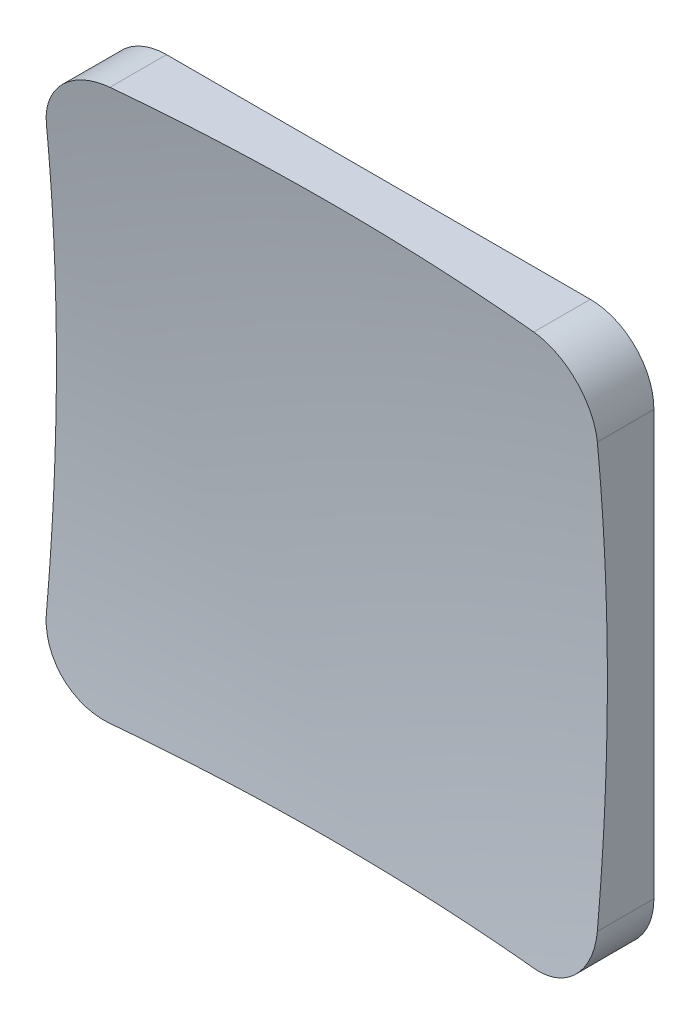
from build123d import *

# Parameters (mm, degrees)
SKETCH1_W           = 130
SKETCH1_H           = 130
BOSS_EXTRUDE1_DEPTH = 15
FILLET1_R           = 15
BOSS_EXTRUDE3_DEPTH = 20
BOSS_EXTRUDE4_DEPTH = 23
CUT_EXTRUDE1_DEPTH  = 50
CUT_EXTRUDE2_DEPTH  = 50
SKETCH10_R          = 3
CUT_EXTRUDE3_DEPTH  = 10


with BuildPart() as part:
    # Sketch1 → Boss-Extrude1 (new body)
    with BuildSketch(Plane.XY):
        Rectangle(SKETCH1_W, SKETCH1_H)
    extrude(amount=BOSS_EXTRUDE1_DEPTH)

    # Fillet1
    fillet1_edges = [part.edges().sort_by_distance(p)[0] for p in [
        (65, -65, 7.5),
        (-65, -65, 7.5),
        (-65, 65, 7.5),
        (65, 65, 7.5),
    ]]
    fillet(fillet1_edges, radius=FILLET1_R)

    # Sketch5 → Boss-Extrude3 (add)
    with BuildSketch(Plane.XY.offset(15)):
        Polygon((-65, 65), (65, -65), (70.504249196, -59.495750804), (-59.495750804, 70.504249196), align=None)
    extrude(amount=BOSS_EXTRUDE3_DEPTH)

    # Sketch6 → Cut-Revolve2 (revolve, cut)
    with BuildSketch(Plane(origin=(0, 0, 0), x_dir=(0, 0, 1), z_dir=(-0.707106781, -0.707106781, 0))):
        with BuildLine():
            Line((15, 91.923881554), (15, 99.514365428))
            Line((15, 99.514365428), (45.882557295, 99.514365428))
            Line((45.882557295, 99.514365428), (45.882557295, 91.923881554))
            Line((45.882557295, 91.923881554), (45.882557295, 0))
            Line((45.882557295, 0), (6.998120304, 0))
            ThreePointArc((6.998120304, 0), (9.00236559, 46.135750993), (15, 91.923881554))
        make_face()
    revolve(axis=Axis((0, 0, 45.882557295), (0, 0, 1)), mode=Mode.SUBTRACT)

    # Sketch7 → Boss-Extrude4 (add)
    with BuildSketch(Plane(origin=(0, 0, 0), x_dir=(-1, 0, 0), z_dir=(0, 0, -1))):
        Polygon((-22, -65), (22, -65), (22, -22), (65, -22), (65, 22), (22, 22), (22, 65), (-22, 65), (-22, 22), (-65, 22), (-65, -22), (-22, -22), align=None)
    extrude(amount=BOSS_EXTRUDE4_DEPTH)

    # Sketch8 → Cut-Extrude1 (cut)
    with BuildSketch(Plane.XZ.offset(22)):
        Polygon((-65, 0), (-55.807611845, -9.192388155), (-45.807611845, -9.192388155), (-40, -23), (0, -40.620002029), (40, -23), (45.807611845, -9.192388155), (55.807611845, -9.192388155), (65, 0), (68.211957708, -1.350979723), (68.682657398, -47.498818865), (-34.338090691, -46.266881669), (-70.140917764, -27.552380355), align=None)
    extrude(amount=-CUT_EXTRUDE1_DEPTH, mode=Mode.SUBTRACT)

    # Sketch9 → Cut-Extrude2 (cut)
    with BuildSketch(Plane(origin=(22, 0, 0), x_dir=(0, 0, -1), z_dir=(1, 0, 0))):
        Polygon((0, 65), (9.192388155, 55.807611845), (9.192388155, 45.807611845), (23, 40), (23, 65), align=None)
    extrude(amount=-CUT_EXTRUDE2_DEPTH, mode=Mode.SUBTRACT)

    # Sketch10 → Cut-Extrude3 (cut)
    with BuildSketch(Plane.XZ.offset(65)):
        with Locations((0, -3)):
            Circle(SKETCH10_R)
    extrude(amount=-CUT_EXTRUDE3_DEPTH, mode=Mode.SUBTRACT)


solid = part.part
